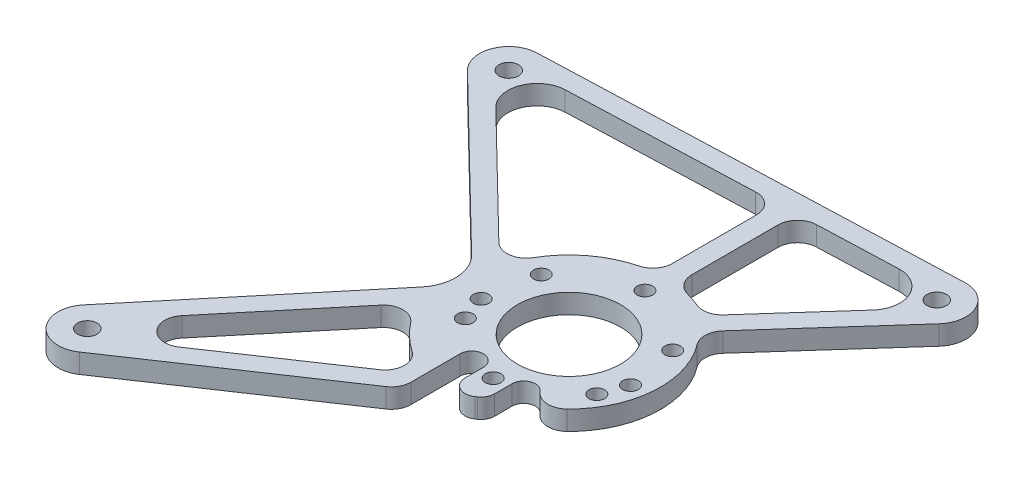
from build123d import *

# Parameters (mm, degrees)
SZKIC3_R                    = 26.5
DODANIE_WYCI_GNI_CIE1_DEPTH = 10
OTW_R1_D                    = 8
OTW_R1_DEPTH                = 10.001
SZYK_KO_OWY1_COUNT          = 18
OTW_R2_D                    = 10
OTW_R2_DEPTH                = 100
OTW_R3_D                    = 10
OTW_R3_DEPTH                = 100
OTW_R4_D                    = 10
OTW_R4_DEPTH                = 10
WYTNIJ_WYCI_GNI_CIE1_DEPTH  = 11
ZAOKR_GLENIE1_R             = 10
OTW_R5_D                    = 10
OTW_R5_DEPTH                = 10
WYTNIJ_WYCI_GNI_CIE2_DEPTH  = 10
ZAOKR_GLENIE2_R             = 10
ZAOKR_GLENIE7_R             = 7


with BuildPart() as part:
    # Szkic3 → Dodanie-wyciągnięcie1 (new body)
    with BuildSketch(Plane(origin=(0, 0, 0), x_dir=(1, 0, 0), z_dir=(0, 1, 0))):
        with BuildLine():
            Line((-1915.5488692, -140.99080739), (-1703.3488692, -133.220934409))
            ThreePointArc((-1703.3488692, -133.220934409), (-1689.223566168, -141.832766807), (-1691.612507096, -158.202886057))
            Line((-1691.612507096, -158.202886057), (-1750, -223.576171044))
            ThreePointArc((-1750, -223.576171044), (-1736.180289372, -268.466810303), (-1768.121254646, -302.904124837))
            Line((-1768.121254646, -302.904124837), (-1899.97553639, -391.673040436))
            ThreePointArc((-1899.97553639, -391.673040436), (-1919.48315677, -389.285445814), (-1919.883316335, -369.636330483))
            Line((-1919.883316335, -369.636330483), (-1840.970754815, -274.791431046))
            ThreePointArc((-1840.970754815, -274.791431046), (-1836.372380588, -260.955992635), (-1842.387744834, -247.675187141))
            Line((-1842.387744834, -247.675187141), (-1925.46803839, -166.72414018))
            ThreePointArc((-1925.46803839, -166.72414018), (-1928.996219751, -150.585779938), (-1915.5488692, -140.99080739))
        make_face()
        with Locations((-1782, -258)):
            Circle(SZKIC3_R, mode=Mode.SUBTRACT)
    extrude(amount=DODANIE_WYCI_GNI_CIE1_DEPTH)

    # Otwór1
    with Locations(Plane(origin=(0, 0, 0), x_dir=(-1, 0, 0), z_dir=(0, -1, 0))):
        with Locations((1782, -219)):
            otw_r1 = Hole(OTW_R1_D / 2, depth=OTW_R1_DEPTH)

    # Szyk kołowy1: Otwór1 ×18 about axis, 10 skipped
    szyk_ko_owy1_axis = Axis((-1782, 10, 258), (0, -1, 0))
    add([otw_r1.rotate(szyk_ko_owy1_axis, i * 360 / SZYK_KO_OWY1_COUNT) for i in range(1, SZYK_KO_OWY1_COUNT) if i not in (1, 2, 4, 7, 8, 10, 11, 14, 16, 17)], mode=Mode.SUBTRACT)

    # Otwór2
    with Locations(Plane(origin=(0, 0, 0), x_dir=(-1, 0, 0), z_dir=(0, -1, 0))):
        with Locations((1702.8, -148.210889132)):
            Hole(OTW_R2_D / 2, depth=OTW_R2_DEPTH)

    # Otwór3
    with Locations(Plane(origin=(0, 0, 0), x_dir=(-1, 0, 0), z_dir=(0, -1, 0))):
        with Locations((1915, -155.980762114)):
            Hole(OTW_R3_D / 2, depth=OTW_R3_DEPTH)

    # Otwór4
    with Locations(Plane(origin=(0, 0, 0), x_dir=(-1, 0, 0), z_dir=(0, -1, 0))):
        with Locations((1908.352535431, -379.230135346)):
            Hole(OTW_R4_D / 2, depth=OTW_R4_DEPTH)

    # Szkic14 → Wytnij-wyciągnięcie1 (cut, through all)
    with BuildSketch(Plane(origin=(0, 0, 0), x_dir=(-1, 0, 0), z_dir=(0, -1, 0))):
        with BuildLine():
            Line((1830.387794708, -245.405504247), (1901.759731773, -175.862742881))
            ThreePointArc((1901.759731773, -175.862742881), (1905.287913135, -159.724382638), (1891.840562583, -150.129410091))
            Line((1891.840562583, -150.129410091), (1787, -146.290588911))
            Line((1787, -146.290588911), (1787, -208.250628145))
            ThreePointArc((1787, -208.250628145), (1814.522074972, -220.02218227), (1830.387794708, -245.405504247))
        make_face()
        with BuildLine():
            Line((1777, -208.250628145), (1777, -145.9244309))
            Line((1777, -145.9244309), (1726.449545971, -144.073485533))
            ThreePointArc((1726.449545971, -144.073485533), (1712.324242939, -152.685317931), (1714.713183868, -169.05543718))
            Line((1714.713183868, -169.05543718), (1756.005588073, -215.288285581))
            ThreePointArc((1756.005588073, -215.288285581), (1766.10831827, -210.592675125), (1777, -208.250628145))
        make_face()
        with BuildLine():
            Line((1889.850904158, -349.175505229), (1834.500977493, -282.650504301))
            ThreePointArc((1834.500977493, -282.650504301), (1820.727394871, -301.176253734), (1800.818732436, -312.86214824))
            Line((1800.818732436, -312.86214824), (1876.579050862, -363.866645198))
            ThreePointArc((1876.579050862, -363.866645198), (1889.584131115, -362.27491545), (1889.850904158, -349.175505229))
        make_face()
    extrude(amount=-WYTNIJ_WYCI_GNI_CIE1_DEPTH, mode=Mode.SUBTRACT)

    # Zaokrąglenie1
    zaokr_glenie1_edges = [part.edges().sort_by_distance(p)[0] for p in [
        (-1800.818732436, 5, 312.86214824),
        (-1834.500977493, 5, 282.650504301),
        (-1777, 5, 208.250628145),
        (-1756.005588073, 5, 215.288285581),
        (-1777, 5, 145.9244309),
        (-1830.387794708, 5, 245.405504247),
        (-1787, 5, 208.250628145),
        (-1787, 5, 146.290588911),
        (-1750, 5, 223.576171044),
        (-1768.121254646, 5, 302.904124837),
    ]]
    fillet(zaokr_glenie1_edges, radius=ZAOKR_GLENIE1_R)

    # Otwór5
    with Locations(Plane(origin=(0, 0, 0), x_dir=(-1, 0, 0), z_dir=(0, -1, 0))):
        with Locations((1795.33878559, -294.648012211), (1768.66121441, -294.648012211)):
            Hole(OTW_R5_D / 2, depth=OTW_R5_DEPTH)

    # Szkic18 → Wytnij-wyciągnięcie2 (cut)
    with BuildSketch(Plane(origin=(0, 0, 0), x_dir=(-1, 0, 0), z_dir=(0, -1, 0))):
        with BuildLine():
            Line((1762.66121441, -294.648012211), (1762.66121441, -300.837032716))
            ThreePointArc((1762.66121441, -300.837032716), (1764.765334946, -301.7260371), (1766.910163713, -302.511760703))
            ThreePointArc((1766.910163713, -302.511760703), (1768.13628585, -303.020458445), (1769.284226275, -303.687078026))
            Line((1769.284226275, -303.687078026), (1774.66121441, -307.307054561))
            Line((1774.66121441, -307.307054561), (1774.66121441, -294.648012211))
            ThreePointArc((1774.66121441, -294.648012211), (1768.66121441, -288.648012211), (1762.66121441, -294.648012211))
        make_face()
        with BuildLine():
            Line((1789.33878559, -294.648012211), (1789.33878559, -317.188508997))
            Line((1789.33878559, -317.188508997), (1801.33878559, -325.267328836))
            Line((1801.33878559, -325.267328836), (1801.33878559, -294.648012211))
            ThreePointArc((1801.33878559, -294.648012211), (1795.33878559, -288.648012211), (1789.33878559, -294.648012211))
        make_face()
    extrude(amount=-WYTNIJ_WYCI_GNI_CIE2_DEPTH, mode=Mode.SUBTRACT)

    # Zaokrąglenie2
    zaokr_glenie2_edges = [part.edges().sort_by_distance(p)[0] for p in [
        (-1762.66121441, 5, 300.837032716),
        (-1801.33878559, 5, 325.267328836),
    ]]
    fillet(zaokr_glenie2_edges, radius=ZAOKR_GLENIE2_R)

    # Zaokrąglenie7
    zaokr_glenie7_edges = [part.edges().sort_by_distance(p)[0] for p in [
        (-1774.66121441, 5, 307.307054561),
        (-1789.33878559, 5, 317.188508997),
    ]]
    fillet(zaokr_glenie7_edges, radius=ZAOKR_GLENIE7_R)


solid = part.part
